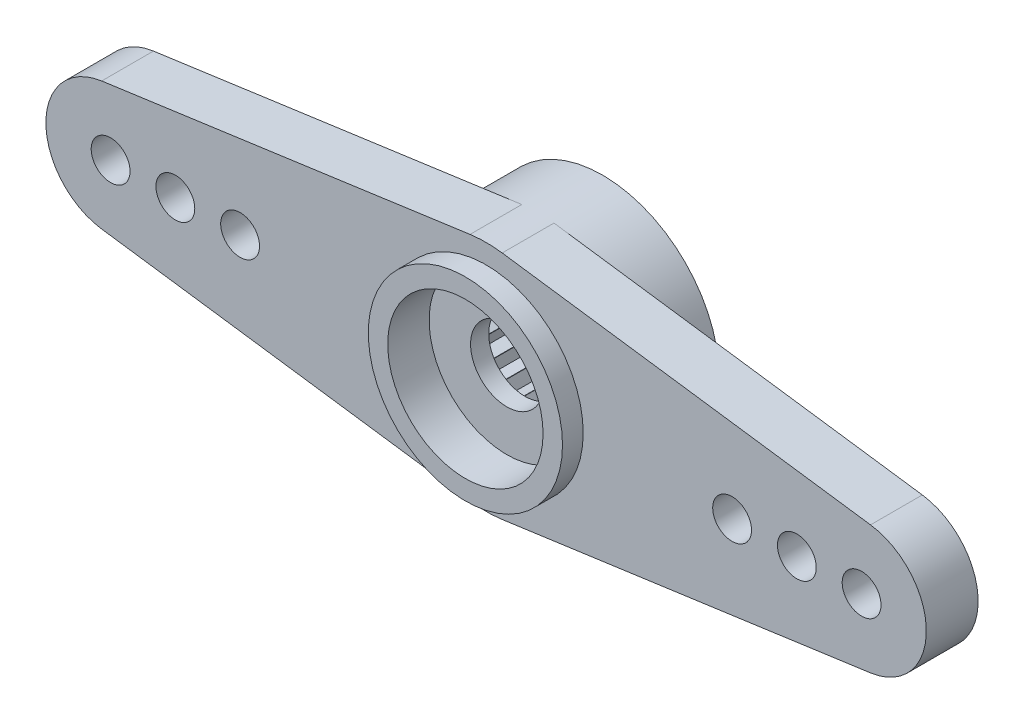
from build123d import *

# Parameters (mm, degrees)
ESQUISSE1_R                  = 4.5
BOSS_EXTRU_1_DEPTH           = 3
BOSS_EXTRU_2_START           = -0.5
ESQUISSE2_R                  = 0.75
BOSS_EXTRU_2_DEPTH           = 2
R_P_TITION_CIRCULAIRE1_COUNT = 2
ESQUISSE5_R                  = 4.5
ESQUISSE5_R_2                = 1.4
BOSS_EXTRU_4_DEPTH           = 0.7
ESQUISSE6_R                  = 4.5
ESQUISSE6_R_2                = 3
BOSS_EXTRU_5_DEPTH           = 0.8
ESQUISSE7_R                  = 3.75
ESQUISSE7_R_2                = 3
BOSS_EXTRU_6_DEPTH           = 0.8


with BuildPart() as part:
    # Esquisse1 → Boss.-Extru.1 (new body)
    with BuildSketch(Plane.XY):
        Circle(ESQUISSE1_R)
        Polygon((2.011577371, -1.550856692), (2.011577371, -2.011577371), (1.550856692, -2.011577371), (1.541643286, -2.018647066), (1.4224, -2.463669069), (0.977377998, -2.344425783), (0.966648759, -2.348869979), (0.73628842, -2.747865791), (0.337292608, -2.517505451), (0.325778716, -2.519021284), (0, -2.8448), (-0.325778716, -2.519021284), (-0.337292608, -2.517505451), (-0.73628842, -2.747865791), (-0.966648759, -2.348869979), (-0.977377998, -2.344425783), (-1.4224, -2.463669069), (-1.541643286, -2.018647066), (-1.550856692, -2.011577371), (-2.011577371, -2.011577371), (-2.011577371, -1.550856692), (-2.018647066, -1.541643286), (-2.463669069, -1.4224), (-2.344425783, -0.977377998), (-2.348869979, -0.966648759), (-2.747865791, -0.73628842), (-2.517505451, -0.337292608), (-2.519021284, -0.325778716), (-2.8448, 0), (-2.519021284, 0.325778716), (-2.517505451, 0.337292608), (-2.747865791, 0.73628842), (-2.348869979, 0.966648759), (-2.344425783, 0.977377998), (-2.463669069, 1.4224), (-2.018647066, 1.541643286), (-2.011577371, 1.550856692), (-2.011577371, 2.011577371), (-1.550856692, 2.011577371), (-1.541643286, 2.018647066), (-1.4224, 2.463669069), (-0.977377998, 2.344425783), (-0.966648759, 2.348869979), (-0.73628842, 2.747865791), (-0.337292608, 2.517505451), (-0.325778716, 2.519021284), (0, 2.8448), (0.325778716, 2.519021284), (0.337292608, 2.517505451), (0.73628842, 2.747865791), (0.966648759, 2.348869979), (0.977377998, 2.344425783), (1.4224, 2.463669069), (1.541643286, 2.018647066), (1.550856692, 2.011577371), (2.011577371, 2.011577371), (2.011577371, 1.550856692), (2.018647066, 1.541643286), (2.463669069, 1.4224), (2.344425783, 0.977377998), (2.348869979, 0.966648759), (2.747865791, 0.73628842), (2.517505451, 0.337292608), (2.519021284, 0.325778716), (2.8448, 0), (2.519021284, -0.325778716), (2.517505451, -0.337292608), (2.747865791, -0.73628842), (2.348869979, -0.966648759), (2.344425783, -0.977377998), (2.463669069, -1.4224), (2.018647066, -1.541643286), align=None, mode=Mode.SUBTRACT)
    extrude(amount=BOSS_EXTRU_1_DEPTH)

    # Esquisse2 → Boss.-Extru.2 (add)
    with BuildSketch(Plane.XY.offset(3).offset(BOSS_EXTRU_2_START)):
        with BuildLine():
            Line((-14.844827586, 2.476104589), (-0.620689655, 4.45698826))
            ThreePointArc((-0.620689655, 4.45698826), (-4.5, 0), (-0.620689655, -4.45698826))
            Line((-0.620689655, -4.45698826), (-14.844827586, -2.476104589))
            ThreePointArc((-14.844827586, -2.476104589), (-17, 0), (-14.844827586, 2.476104589))
        make_face()
        with Locations((-14.5, 0)):
            Circle(ESQUISSE2_R, mode=Mode.SUBTRACT)
        with Locations((-12, 0)):
            Circle(ESQUISSE2_R, mode=Mode.SUBTRACT)
        with Locations((-9.5, 0)):
            Circle(ESQUISSE2_R, mode=Mode.SUBTRACT)
    boss_extru_2 = extrude(amount=BOSS_EXTRU_2_DEPTH)

    # Répétition circulaire1: Boss.-Extru.2 ×2 about axis
    r_p_tition_circulaire1_axis = Axis((0, 0, 0), (0, 0, 1))
    for i in range(1, R_P_TITION_CIRCULAIRE1_COUNT):
        add(boss_extru_2.rotate(r_p_tition_circulaire1_axis, i * 360 / R_P_TITION_CIRCULAIRE1_COUNT))

    # Esquisse5 → Boss.-Extru.4 (add)
    with BuildSketch(Plane.XY.offset(3)):
        Circle(ESQUISSE5_R)
        Circle(ESQUISSE5_R_2, mode=Mode.SUBTRACT)
    extrude(amount=BOSS_EXTRU_4_DEPTH)

    # Esquisse6 → Boss.-Extru.5 (add)
    with BuildSketch(Plane.XY.offset(3.7)):
        Circle(ESQUISSE6_R)
        Circle(ESQUISSE6_R_2, mode=Mode.SUBTRACT)
    extrude(amount=BOSS_EXTRU_5_DEPTH)

    # Esquisse7 → Boss.-Extru.6 (add)
    with BuildSketch(Plane.XY.offset(4.5)):
        Circle(ESQUISSE7_R)
        Circle(ESQUISSE7_R_2, mode=Mode.SUBTRACT)
    extrude(amount=BOSS_EXTRU_6_DEPTH)


solid = part.part
